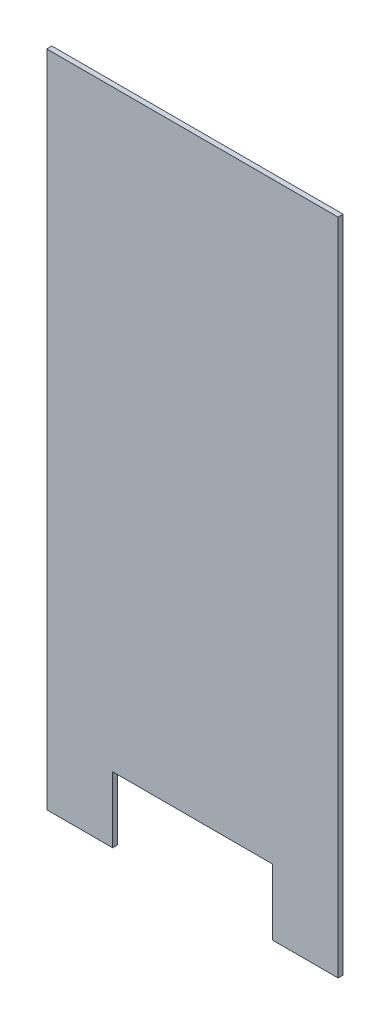
from build123d import *

# Parameters (mm, degrees)
BOSS_EXTRUDE1_DEPTH = 10


with BuildPart() as part:
    # Sketch1 → Boss-Extrude1 (new body)
    with BuildSketch(Plane.XY):
        Polygon((-287.5, 650.25), (287.5, 650.25), (287.5, -650.25), (157.5, -650.25), (157.5, -520.25), (-157.5, -520.25), (-157.5, -650.25), (-287.5, -650.25), align=None)
    extrude(amount=BOSS_EXTRUDE1_DEPTH)


solid = part.part
